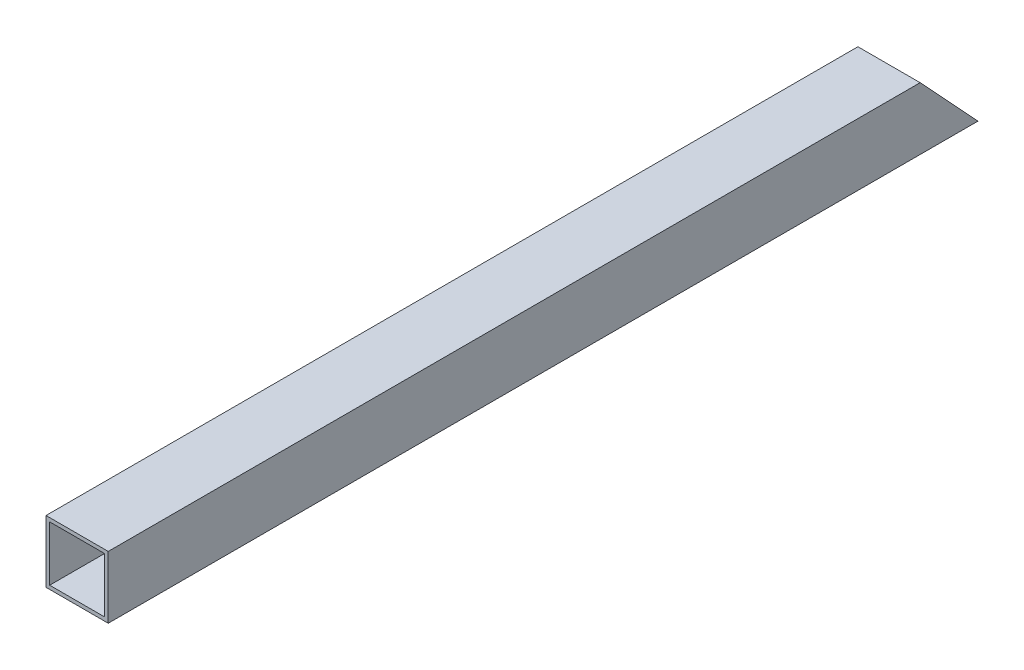
from build123d import *

# Parameters (mm, degrees)
SKETCH1_W           = 25.4
SKETCH1_H           = 25.4
SKETCH1_W_2         = 22.4
SKETCH1_H_2         = 22.4
BOSS_EXTRUDE1_DEPTH = 355
CUT_EXTRUDE2_DEPTH  = 25.4


with BuildPart() as part:
    # Sketch1 → Boss-Extrude1 (new body)
    with BuildSketch(Plane.XY):
        Rectangle(SKETCH1_W, SKETCH1_H)
        Rectangle(SKETCH1_W_2, SKETCH1_H_2, mode=Mode.SUBTRACT)
    extrude(amount=BOSS_EXTRUDE1_DEPTH)

    # Sketch3 → Cut-Extrude2 (cut)
    with BuildSketch(Plane.ZY.offset(12.7)):
        Polygon((0, -12.7), (23.62, 12.7), (0, 12.7), align=None)
    extrude(amount=-CUT_EXTRUDE2_DEPTH, mode=Mode.SUBTRACT)


solid = part.part
